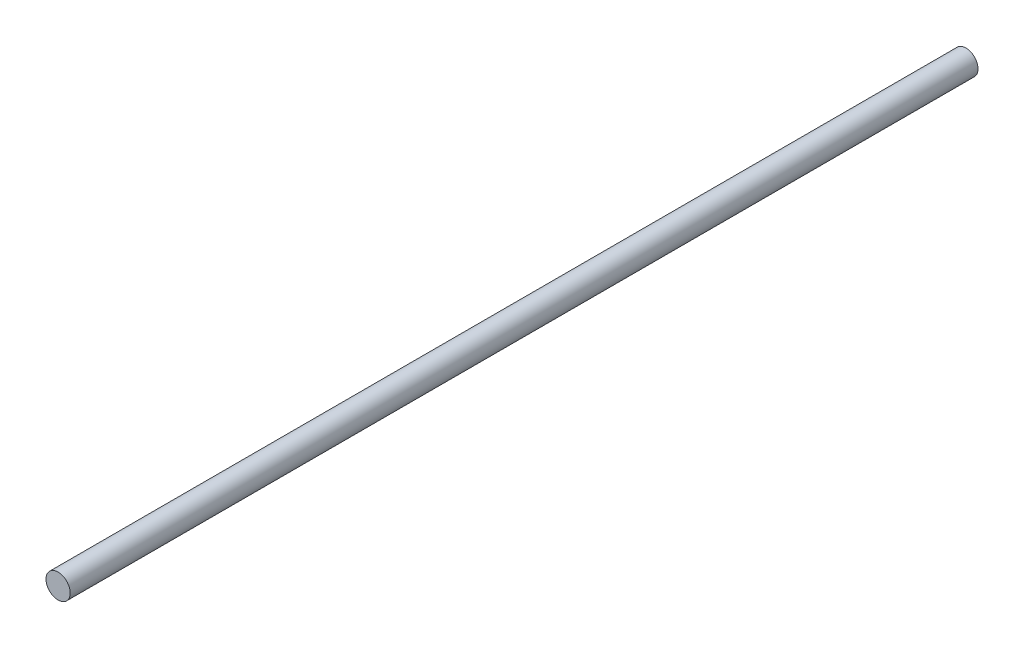
from build123d import *

# Parameters (mm, degrees)
SKETCH1_R                = 2
BOSS_EXTRUDE1_DEPTH      = 100
BOSS_EXTRUDE1_DEPTH_BACK = 50


with BuildPart() as part:
    # Sketch1 → Boss-Extrude1 (new body, two sides)
    with BuildSketch(Plane.XY) as boss_extrude1_sk:
        Circle(SKETCH1_R)
    extrude(amount=BOSS_EXTRUDE1_DEPTH)
    extrude(boss_extrude1_sk.sketch, amount=-BOSS_EXTRUDE1_DEPTH_BACK)


solid = part.part
